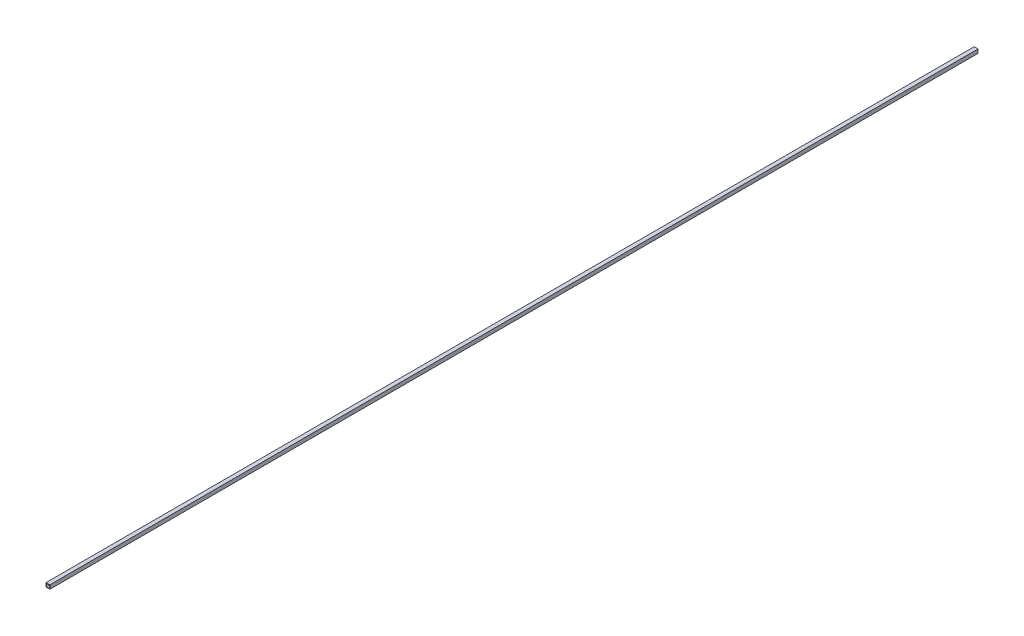
from build123d import *

# Parameters (mm, degrees)
SKETCH1_W           = 6.35
SKETCH1_H           = 6.35
SKETCH1_R           = 2.54
BOSS_EXTRUDE1_DEPTH = 1524


with BuildPart() as part:
    # Sketch1 → Boss-Extrude1 (new body)
    with BuildSketch(Plane.XY):
        Rectangle(SKETCH1_W, SKETCH1_H)
        Circle(SKETCH1_R, mode=Mode.SUBTRACT)
    extrude(amount=BOSS_EXTRUDE1_DEPTH)


solid = part.part
